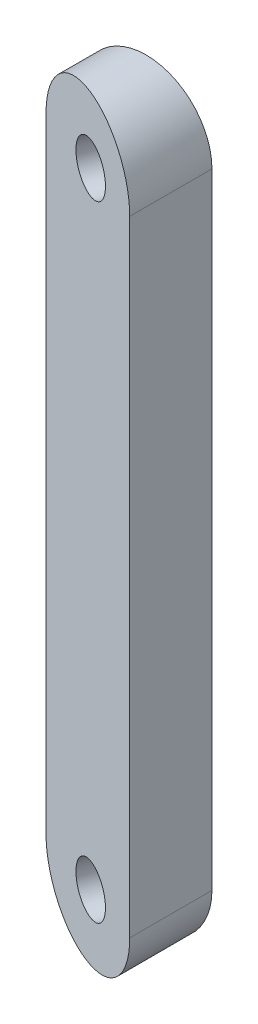
from build123d import *

# Parameters (mm, degrees)
BOSS_EXTRUDE1_DEPTH     = 5
CUT_EXTRUDE1_DEPTH      = 24
CUT_EXTRUDE1_DEPTH_BACK = 24
SKETCH3_R               = 1.5
CUT_EXTRUDE2_DEPTH      = 91


with BuildPart() as part:
    # Sketch1 → Boss-Extrude1 (new body)
    with BuildSketch(Plane.XY):
        with BuildLine():
            Line((72.394590039, 19), (72.394590039, -19))
            ThreePointArc((72.394590039, -19), (68.394590039, -23), (64.394590039, -19))
            Line((64.394590039, -19), (64.394590039, 19))
            ThreePointArc((64.394590039, 19), (68.394590039, 23), (72.394590039, 19))
        make_face()
    extrude(amount=BOSS_EXTRUDE1_DEPTH)

    # Sketch2 → Cut-Extrude1 (cut, two sides)
    with BuildSketch(Plane(origin=(0, 0, 0), x_dir=(1, 0, 0), z_dir=(0, 1, 0))) as cut_extrude1_sk:
        Polygon((72.394590039, -5), (64.394590039, -2.088238126), (64.394590039, -5), align=None)
    extrude(amount=CUT_EXTRUDE1_DEPTH, mode=Mode.SUBTRACT)
    extrude(cut_extrude1_sk.sketch, amount=-CUT_EXTRUDE1_DEPTH_BACK, mode=Mode.SUBTRACT)

    # Sketch3 → Cut-Extrude2 (cut)
    with BuildSketch(Plane(origin=(6.86158929, 0, -18.852061635), x_dir=(0.939692621, 0, 0.342020143), z_dir=(-0.342020143, 0, 0.939692621))):
        with Locations((65.769891562, 19)):
            Circle(SKETCH3_R)
        with Locations((65.769891562, -19)):
            Circle(SKETCH3_R)
    extrude(amount=-CUT_EXTRUDE2_DEPTH, mode=Mode.SUBTRACT)


solid = part.part
